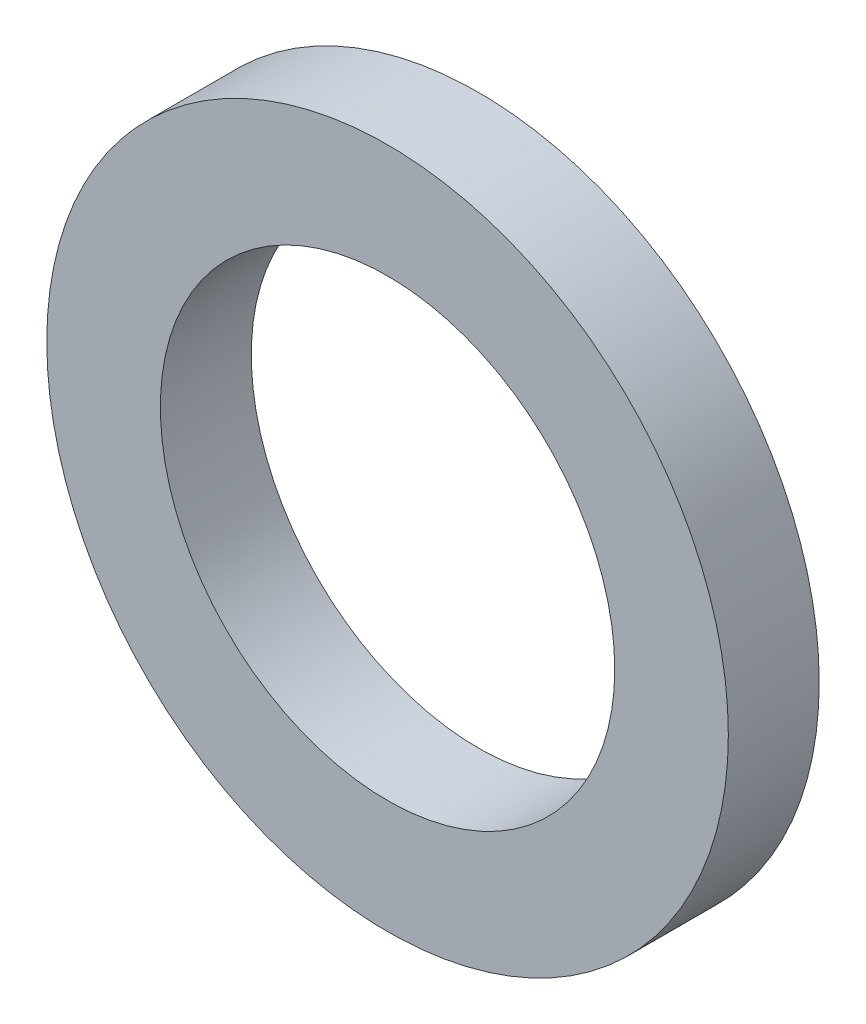
from build123d import *

# Parameters (mm, degrees)
SKETCH1_R           = 9.525
SKETCH1_R_2         = 6.35
BOSS_EXTRUDE1_DEPTH = 2.54


with BuildPart() as part:
    # Sketch1 → Boss-Extrude1 (new body)
    with BuildSketch(Plane.XY):
        Circle(SKETCH1_R)
        Circle(SKETCH1_R_2, mode=Mode.SUBTRACT)
    extrude(amount=BOSS_EXTRUDE1_DEPTH)


solid = part.part
